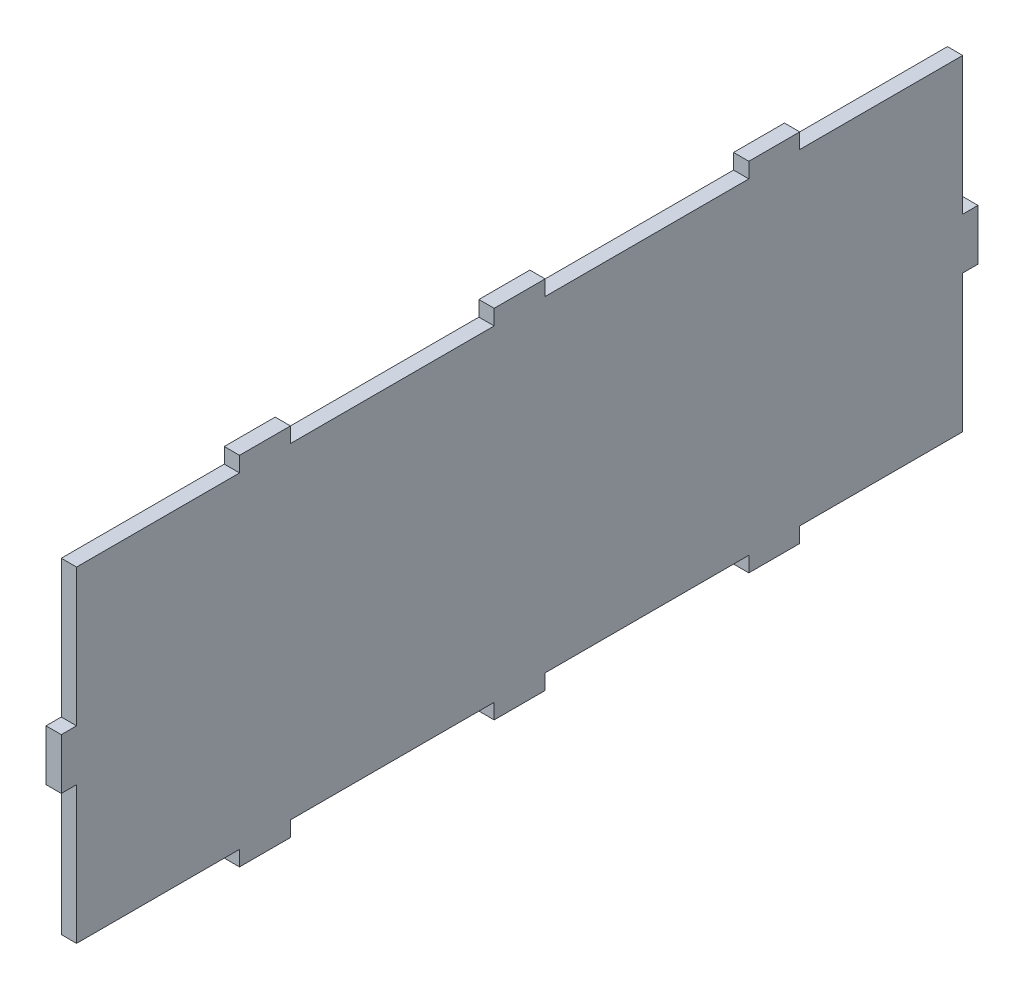
from build123d import *

# Parameters (mm, degrees)
SKETCH1_W           = 180
SKETCH1_H           = 70
BOSS_EXTRUDE1_DEPTH = 3
SKETCH2_W           = 3
SKETCH2_H           = 27
SKETCH2_W_2         = 40
SKETCH2_H_2         = 3
CUT_EXTRUDE6_DEPTH  = 10


with BuildPart() as part:
    # Sketch1 → Boss-Extrude1 (new body)
    with BuildSketch(Plane(origin=(0, 0, 0), x_dir=(0, 0, -1), z_dir=(1, 0, 0))):
        Rectangle(SKETCH1_W, SKETCH1_H)
    extrude(amount=BOSS_EXTRUDE1_DEPTH)

    # Sketch2 → Cut-Extrude6 (cut)
    with BuildSketch(Plane(origin=(3, 0, 0), x_dir=(0, 0, -1), z_dir=(1, 0, 0))):
        Polygon((90, -32), (87, -32), (55, -32), (55, -35), (90, -35), align=None)
        with Locations((88.5, -18.5)):
            Rectangle(SKETCH2_W, SKETCH2_H)
        with Locations((25, -33.5)):
            Rectangle(SKETCH2_W_2, SKETCH2_H_2)
        with Locations((-25, -33.5)):
            Rectangle(SKETCH2_W_2, SKETCH2_H_2)
        Polygon((-55, -32), (-87, -32), (-90, -32), (-90, -35), (-55, -35), align=None)
        with Locations((-88.5, -18.5)):
            Rectangle(SKETCH2_W, SKETCH2_H)
        with Locations((-88.5, 18.5)):
            Rectangle(SKETCH2_W, SKETCH2_H)
        Polygon((-87, 32), (-55, 32), (-55, 35), (-90, 35), (-90, 32), align=None)
        with Locations((-25, 33.5)):
            Rectangle(SKETCH2_W_2, SKETCH2_H_2)
        with Locations((25, 33.5)):
            Rectangle(SKETCH2_W_2, SKETCH2_H_2)
        Polygon((55, 32), (87, 32), (90, 32), (90, 35), (55, 35), align=None)
        with Locations((88.5, 18.5)):
            Rectangle(SKETCH2_W, SKETCH2_H)
    extrude(amount=-CUT_EXTRUDE6_DEPTH, mode=Mode.SUBTRACT)


solid = part.part
